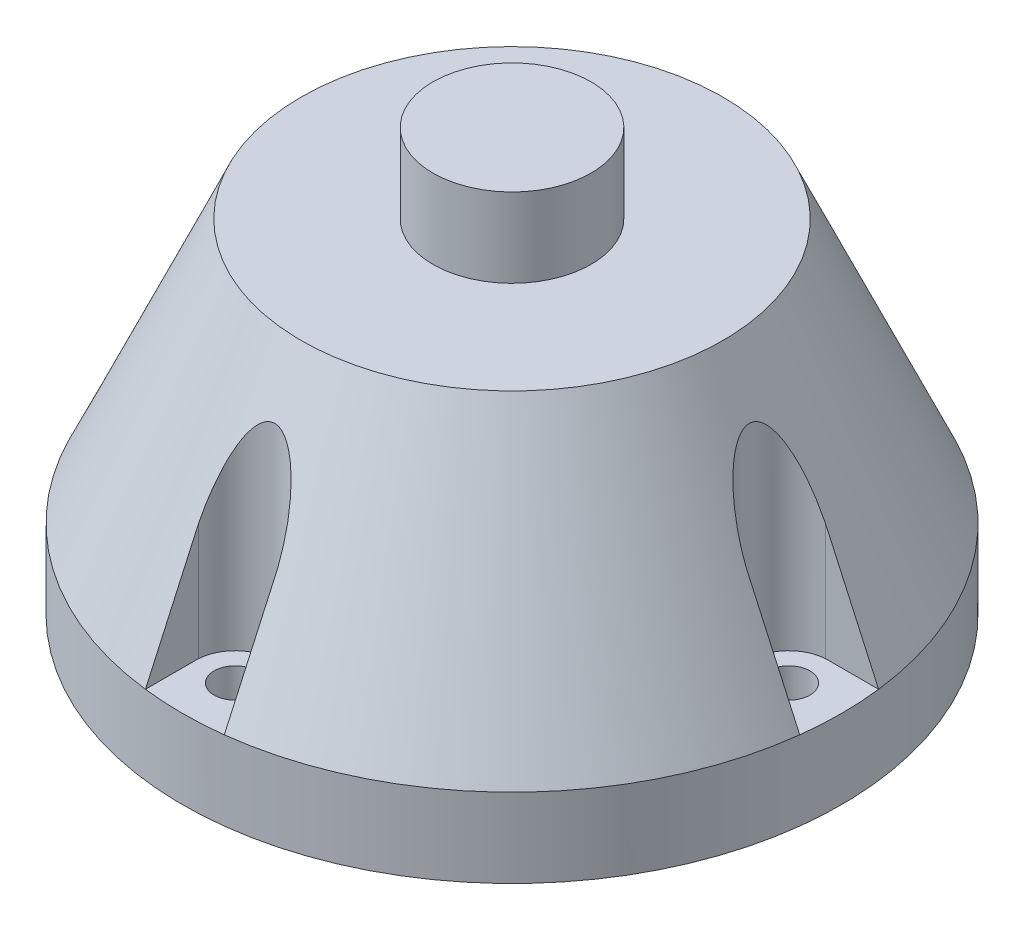
from build123d import *

# Parameters (mm, degrees)
SKETCH4_R           = 62.5
SKETCH4_R_2         = 4
BOSS_EXTRUDE2_DEPTH = 15
CUT_EXTRUDE1_REACH  = 111.716


with BuildPart() as part:
    # Sketch3 → Revolve1 (revolve)
    with BuildSketch(Plane.XY):
        Polygon((0, 15), (62.5, 15), (40, 65), (15, 65), (15, 80), (0, 80), (0, 65), align=None)
    revolve(axis=Axis((0, 65, 0), (0, -1, 0)))

    # Sketch4 → Boss-Extrude2 (add)
    with BuildSketch(Plane.XZ.offset(-15)):
        Circle(SKETCH4_R)
        with Locations((0, -52.5)):
            Circle(SKETCH4_R_2, mode=Mode.SUBTRACT)
        with Locations((-52.5, 0)):
            Circle(SKETCH4_R_2, mode=Mode.SUBTRACT)
        with Locations((0, 52.5)):
            Circle(SKETCH4_R_2, mode=Mode.SUBTRACT)
        with Locations((52.5, 0)):
            Circle(SKETCH4_R_2, mode=Mode.SUBTRACT)
    extrude(amount=BOSS_EXTRUDE2_DEPTH)

    # Sketch4_5 → Cut-Extrude1 (cut, up to next)
    with BuildSketch(Plane.XZ.offset(-15), mode=Mode.PRIVATE) as cut_extrude1_sk1:
        with BuildLine():
            Line((7.480842881, -62.050680817), (7.480842881, -51.964285714))
            ThreePointArc((7.480842881, -51.964285714), (0, -45), (-7.480842881, -51.964285714))
            Line((-7.480842881, -51.964285714), (-7.480842881, -62.050680817))
            ThreePointArc((-7.480842881, -62.050680817), (0, -62.5), (7.480842881, -62.050680817))
        make_face()
    cut_extrude1_tool1 = extrude(cut_extrude1_sk1.sketch, amount=-CUT_EXTRUDE1_REACH, mode=Mode.PRIVATE) & part.part
    # Sketch4_5 → Cut-Extrude1 (cut, up to next)
    with BuildSketch(Plane.XZ.offset(-15), mode=Mode.PRIVATE) as cut_extrude1_sk2:
        with BuildLine():
            Line((51.964285714, -7.480842881), (62.050680817, -7.480842881))
            ThreePointArc((62.050680817, -7.480842881), (62.5, 0), (62.050680817, 7.480842881))
            Line((62.050680817, 7.480842881), (51.964285714, 7.480842881))
            ThreePointArc((51.964285714, 7.480842881), (45, 0), (51.964285714, -7.480842881))
        make_face()
    cut_extrude1_tool2 = extrude(cut_extrude1_sk2.sketch, amount=-CUT_EXTRUDE1_REACH, mode=Mode.PRIVATE) & part.part
    # Sketch4_5 → Cut-Extrude1 (cut, up to next)
    with BuildSketch(Plane.XZ.offset(-15), mode=Mode.PRIVATE) as cut_extrude1_sk3:
        with BuildLine():
            ThreePointArc((-62.050680817, 7.480842881), (-62.5, 0), (-62.050680817, -7.480842881))
            Line((-62.050680817, -7.480842881), (-51.964285714, -7.480842881))
            ThreePointArc((-51.964285714, -7.480842881), (-45, 0), (-51.964285714, 7.480842881))
            Line((-51.964285714, 7.480842881), (-62.050680817, 7.480842881))
        make_face()
    cut_extrude1_tool3 = extrude(cut_extrude1_sk3.sketch, amount=-CUT_EXTRUDE1_REACH, mode=Mode.PRIVATE) & part.part
    # Sketch4_5 → Cut-Extrude1 (cut, up to next)
    with BuildSketch(Plane.XZ.offset(-15), mode=Mode.PRIVATE) as cut_extrude1_sk4:
        with BuildLine():
            ThreePointArc((7.480842881, 62.050680817), (0, 62.5), (-7.480842881, 62.050680817))
            Line((-7.480842881, 62.050680817), (-7.480842881, 51.964285714))
            ThreePointArc((-7.480842881, 51.964285714), (0, 45), (7.480842881, 51.964285714))
            Line((7.480842881, 51.964285714), (7.480842881, 62.050680817))
        make_face()
    cut_extrude1_tool4 = extrude(cut_extrude1_sk4.sketch, amount=-CUT_EXTRUDE1_REACH, mode=Mode.PRIVATE) & part.part
    add(cut_extrude1_tool1.solids().sort_by_distance((0, 15, -54.386802))[0], mode=Mode.SUBTRACT)
    add(cut_extrude1_tool2.solids().sort_by_distance((54.386802, 15, 0))[0], mode=Mode.SUBTRACT)
    add(cut_extrude1_tool3.solids().sort_by_distance((-54.386802, 15, 0))[0], mode=Mode.SUBTRACT)
    add(cut_extrude1_tool4.solids().sort_by_distance((0, 15, 54.386802))[0], mode=Mode.SUBTRACT)


solid = part.part
